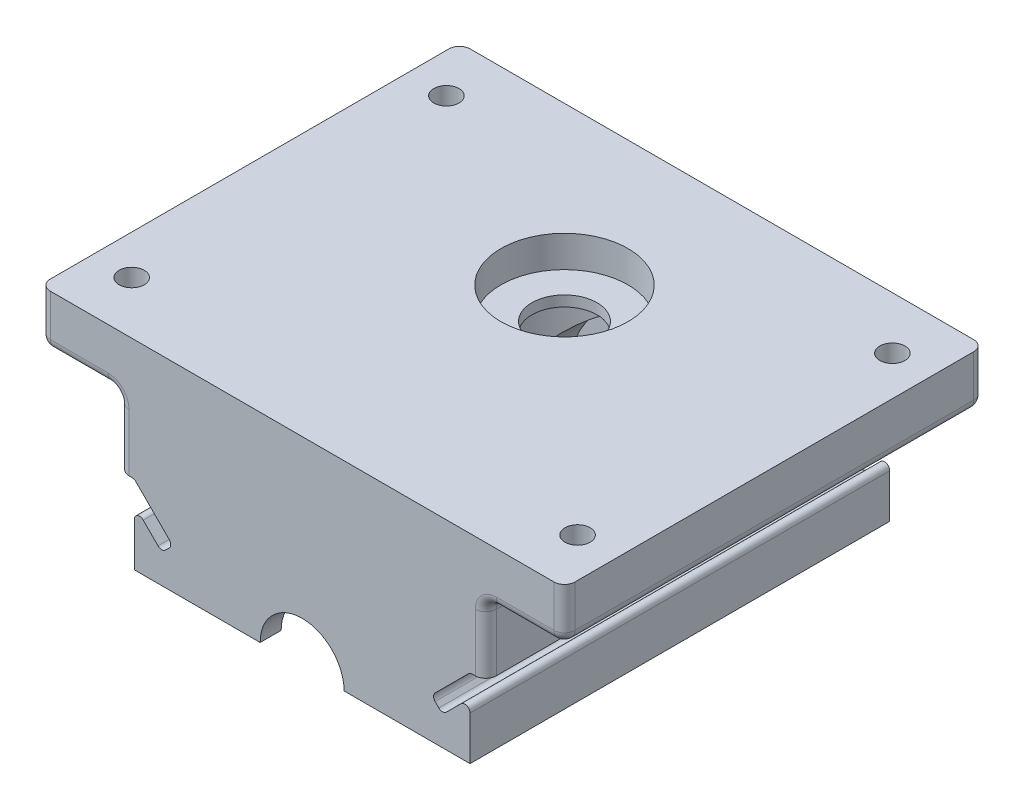
from build123d import *

# Parameters (mm, degrees)
ESQUISSE1_W                                       = 100
ESQUISSE1_H                                       = 80
BOSS_EXTRU_1_DEPTH                                = 10
ESQUISSE2_W                                       = 70
ESQUISSE2_H                                       = 80
BOSS_EXTRU_2_DEPTH                                = 28
BOSS_EXTRU_3_DEPTH                                = 6.15
ESQUISSE3_W                                       = 8
ESQUISSE3_H                                       = 4
ESQUISSE4_R                                       = 21
ENL_V_MAT_EXTRU_1_DEPTH                           = 30
ESQUISSE5_R                                       = 12.1
ENL_V_MAT_EXTRU_2_DEPTH                           = 6
ESQUISSE6_R                                       = 6.2
ENL_V_MAT_EXTRU_3_DEPTH                           = 33.0000001
ENL_V_MAT_EXTRU_5_DEPTH                           = 87.15
CHAMBRAGE_POUR_VIS_SIX_PANS_CREUX_M41_D           = 4.8
CHAMBRAGE_POUR_VIS_SIX_PANS_CREUX_M41_CBORE_D     = 8
CHAMBRAGE_POUR_VIS_SIX_PANS_CREUX_M41_CBORE_DEPTH = 4.4
CONG_1_R                                          = 2


with BuildPart() as part:
    # Esquisse1 → Boss.-Extru.1 (new body)
    with BuildSketch(Plane(origin=(0, 0, 0), x_dir=(1, 0, 0), z_dir=(0, 1, 0))):
        with Locations((50, 40)):
            Rectangle(ESQUISSE1_W, ESQUISSE1_H)
    extrude(amount=BOSS_EXTRU_1_DEPTH)

    # Esquisse2 → Boss.-Extru.2 (add)
    with BuildSketch(Plane.XZ):
        with Locations((50, -40)):
            Rectangle(ESQUISSE2_W, ESQUISSE2_H)
    extrude(amount=BOSS_EXTRU_2_DEPTH)

    # Esquisse11 → Boss.-Extru.3 (add)
    with BuildSketch(Plane(origin=(0, 0, -80), x_dir=(-1, 0, 0), z_dir=(0, 0, -1))):
        with BuildLine():
            Line((-70, -28), (-30, -28))
            ThreePointArc((-30, -28), (-50, -8), (-70, -28))
        make_face()
    extrude(amount=BOSS_EXTRU_3_DEPTH)

    # Esquisse3 → Enlèvement de matière-Révolution1 (revolve, cut)
    with BuildSketch(Plane(origin=(0, -28, -30), x_dir=(1, 0, 0), z_dir=(0, 1, 0))):
        with Locations((54, -28)):
            Rectangle(ESQUISSE3_W, ESQUISSE3_H)
        Polygon((58, -19.8), (50, -19.8), (50, -26), (58, -26), (62, -26), (62, -19.8), align=None)
        with Locations((54, -17.8)):
            Rectangle(ESQUISSE3_W, ESQUISSE3_H)
        Polygon((58, 41.95), (50, 41.95), (50, -15.8), (58, -15.8), (71.5, -15.8), (71.5, 41.95), align=None)
        with Locations((54, 43.95)):
            Rectangle(ESQUISSE3_W, ESQUISSE3_H)
        Polygon((62, 52.15), (50, 52.15), (50, 45.95), (58, 45.95), (62, 45.95), align=None)
    revolve(axis=Axis((50, -28, -86.15), (0, 0, 1)), mode=Mode.SUBTRACT)

    # Esquisse4 → Enlèv. mat.-Extru.1 (cut)
    with BuildSketch(Plane(origin=(0, -28, 0), x_dir=(-1, 0, 0), z_dir=(0, -1, 0))):
        with Locations((-50, 50)):
            Circle(ESQUISSE4_R)
    extrude(amount=-ENL_V_MAT_EXTRU_1_DEPTH, mode=Mode.SUBTRACT)

    # Esquisse5 → Enlèv. mat.-Extru.2 (cut)
    with BuildSketch(Plane(origin=(0, 10, 0), x_dir=(1, 0, 0), z_dir=(0, 1, 0))):
        with Locations((50, 50)):
            Circle(ESQUISSE5_R)
    extrude(amount=-ENL_V_MAT_EXTRU_2_DEPTH, mode=Mode.SUBTRACT)

    # Esquisse6 → Enlèv. mat.-Extru.3 (cut, through all)
    with BuildSketch(Plane(origin=(0, 4, 0), x_dir=(1, 0, 0), z_dir=(0, 1, 0))):
        with Locations((50, 50)):
            Circle(ESQUISSE6_R)
    extrude(amount=-ENL_V_MAT_EXTRU_3_DEPTH, mode=Mode.SUBTRACT)

    # Esquisse7 → Enlèv. mat.-Extru.5 (cut, through all)
    with BuildSketch(Plane.XY):
        with BuildLine():
            Line((24.656854249, -19.656854249), (18.292893219, -13.292893219))
            ThreePointArc((18.292893219, -13.292893219), (17.96846987, -13.076120467), (17.585786438, -13))
            Line((17.585786438, -13), (15, -13))
            Line((15, -13), (15, -28))
            Line((15, -28), (18, -28))
            Line((18, -28), (18, -19.656854249))
            ThreePointArc((18, -19.656854249), (18.617316568, -18.732974717), (19.707106781, -18.949747468))
            Line((19.707106781, -18.949747468), (22.535533906, -21.778174593))
            ThreePointArc((22.535533906, -21.778174593), (23.242640687, -22.071067812), (23.949747468, -21.778174593))
            Line((23.949747468, -21.778174593), (24.656854249, -21.071067812))
            ThreePointArc((24.656854249, -21.071067812), (24.949747468, -20.363961031), (24.656854249, -19.656854249))
        make_face()
        with BuildLine():
            Line((82, -19.656854249), (82, -28))
            Line((82, -28), (85, -28))
            Line((85, -28), (85, -13))
            Line((85, -13), (82.414213562, -13))
            ThreePointArc((82.414213562, -13), (82.03153013, -13.076120467), (81.707106781, -13.292893219))
            Line((81.707106781, -13.292893219), (75.343145751, -19.656854249))
            ThreePointArc((75.343145751, -19.656854249), (75.050252532, -20.363961031), (75.343145751, -21.071067812))
            Line((75.343145751, -21.071067812), (76.050252532, -21.778174593))
            ThreePointArc((76.050252532, -21.778174593), (76.757359313, -22.071067812), (77.464466094, -21.778174593))
            Line((77.464466094, -21.778174593), (80.292893219, -18.949747468))
            ThreePointArc((80.292893219, -18.949747468), (81.382683432, -18.732974717), (82, -19.656854249))
        make_face()
    extrude(amount=-ENL_V_MAT_EXTRU_5_DEPTH, mode=Mode.SUBTRACT)

    # Chambrage pour vis à six pans creux M41 (through all)
    with Locations(Plane(origin=(7.5, 0, -10), x_dir=(0, 0, -1), z_dir=(0, -1, 0))):
        with Locations((0, 0), (60, 0), (60, 85), (0, 85)):
            CounterBoreHole(CHAMBRAGE_POUR_VIS_SIX_PANS_CREUX_M41_D / 2, CHAMBRAGE_POUR_VIS_SIX_PANS_CREUX_M41_CBORE_D / 2, CHAMBRAGE_POUR_VIS_SIX_PANS_CREUX_M41_CBORE_DEPTH)

    # Congé1
    cong_1_edges = [part.edges().sort_by_distance(p)[0] for p in [
        (92.5, 0, 0),
        (92.5, 0, -80),
        (15, 0, -40),
        (85, 0, -40),
        (50, -8, -80),
        (50, -8, -86.15),
        (0, 0, -40),
        (7.5, 0, -80),
        (100, 0, -40),
        (7.5, 0, 0),
        (0, 5, 0),
        (0, 5, -80),
        (100, 5, -80),
        (100, 5, 0),
        (85, -6.5, 0),
        (85, -6.5, -80),
        (15, -6.5, -80),
        (15, -6.5, 0),
    ]]
    fillet(cong_1_edges, radius=CONG_1_R)


solid = part.part
